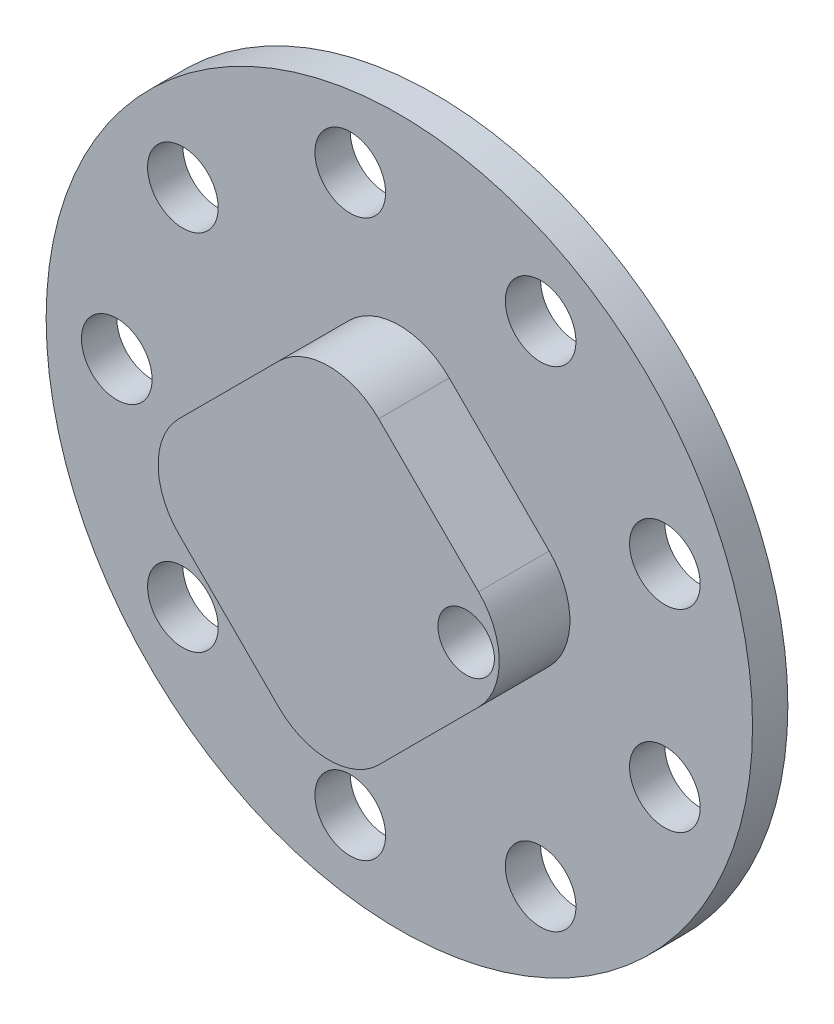
from build123d import *

# Parameters (mm, degrees)
SKICA1_R                 = 50
VYSUNOUT1_DEPTH          = 5
SKICA3_R                 = 5
ODEBRAT_VYSUNUT_M1_DEPTH = 6
KRUHOV_POLE1_COUNT       = 9
VYSUNOUT2_DEPTH          = 10
ZAOBLIT2_R               = 10
ODEBRAT_VYSUNUT_M2_REACH = 17
SKICA5_R                 = 4


with BuildPart() as part:
    # Skica1 → Vysunout1 (new body)
    with BuildSketch(Plane.XY):
        Circle(SKICA1_R)
    extrude(amount=VYSUNOUT1_DEPTH)

    # Skica3 → Odebrat vysunutím1 (cut, through all)
    with BuildSketch(Plane.XY.offset(5)):
        with Locations((-40, 0)):
            Circle(SKICA3_R)
    odebrat_vysunut_m1 = extrude(amount=-ODEBRAT_VYSUNUT_M1_DEPTH, mode=Mode.SUBTRACT)

    # Kruhové pole1: Odebrat vysunutím1 ×9 about axis
    kruhov_pole1_axis = Axis((0, 0, 0), (0, 0, 1))
    for i in range(1, KRUHOV_POLE1_COUNT):
        add(odebrat_vysunut_m1.rotate(kruhov_pole1_axis, i * 360 / KRUHOV_POLE1_COUNT), mode=Mode.SUBTRACT)

    # Skica2 → Vysunout2 (add)
    with BuildSketch(Plane.XY.offset(5)):
        Polygon((0, 28.284271247), (-28.284271247, 0), (0, -28.284271247), (28.284271247, 0), align=None)
    extrude(amount=VYSUNOUT2_DEPTH)

    # Zaoblit2
    zaoblit2_edges = [part.edges().sort_by_distance(p)[0] for p in [
        (-28.284271247, 0, 10),
        (0, -28.284271247, 10),
        (28.284271247, 0, 10),
        (0, 28.284271247, 10),
    ]]
    fillet(zaoblit2_edges, radius=ZAOBLIT2_R)

    # Skica5 → Odebrat vysunutím2 (cut, up to next)
    with BuildSketch(Plane.XY.offset(15), mode=Mode.PRIVATE) as odebrat_vysunut_m2_sk1:
        with Locations((19.460353897, 0)):
            Circle(SKICA5_R)
    odebrat_vysunut_m2_tool1 = extrude(odebrat_vysunut_m2_sk1.sketch, amount=-ODEBRAT_VYSUNUT_M2_REACH, mode=Mode.PRIVATE) & part.part
    add(odebrat_vysunut_m2_tool1.solids().sort_by_distance((19.460354, 0, 15))[0], mode=Mode.SUBTRACT)


solid = part.part
